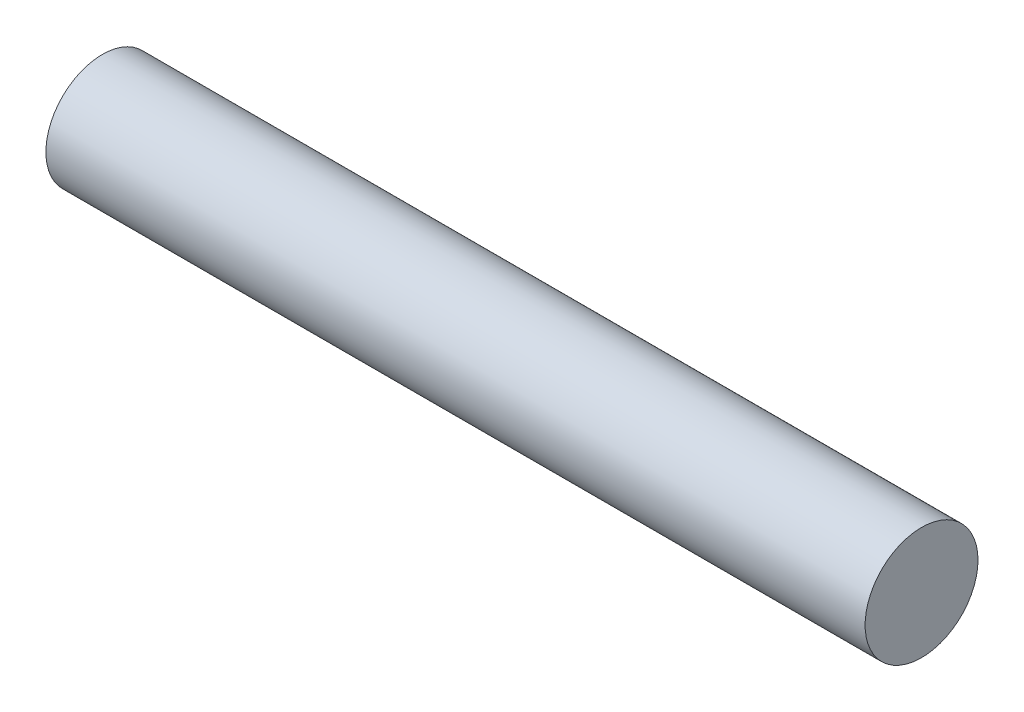
from build123d import *

# Parameters (mm, degrees)
SKETCH1_R           = 0.175
BOSS_EXTRUDE1_DEPTH = 2.54


with BuildPart() as part:
    # Sketch1 → Boss-Extrude1 (new body)
    with BuildSketch(Plane(origin=(0, 0, 0), x_dir=(0, 0, -1), z_dir=(1, 0, 0))):
        Circle(SKETCH1_R)
    extrude(amount=BOSS_EXTRUDE1_DEPTH)


solid = part.part
